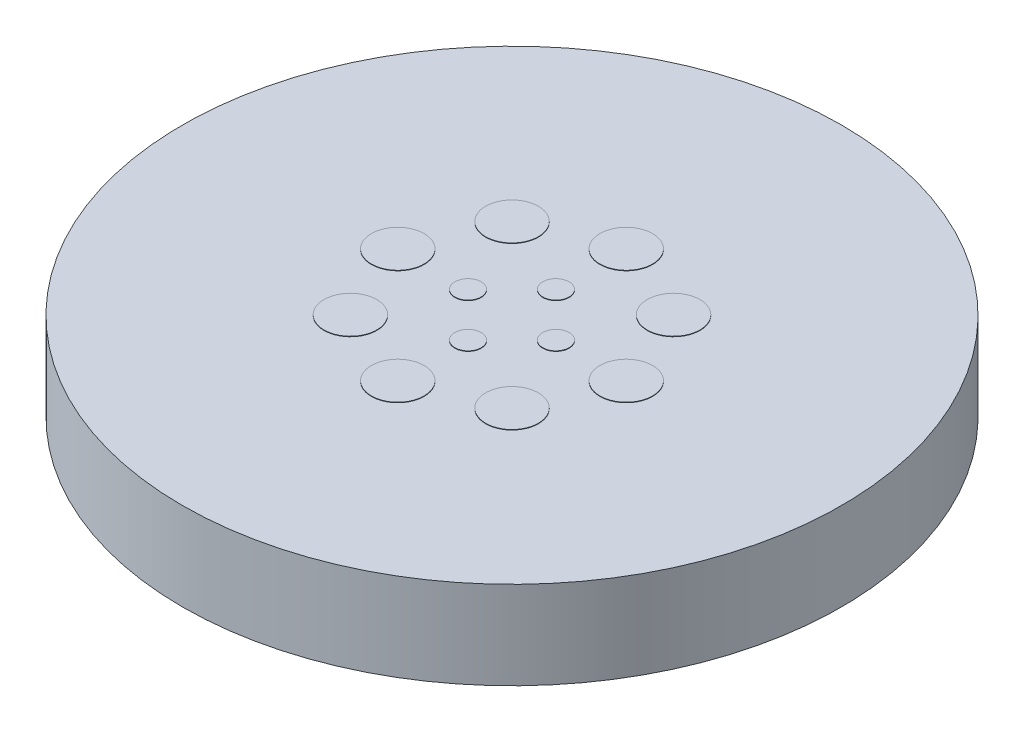
from build123d import *

# Parameters (mm, degrees)
SKETCH1_R           = 50.8
BOSS_EXTRUDE1_DEPTH = 25.4
SKETCH2_R           = 69.85
SKETCH2_R_2         = 50.8
BOSS_EXTRUDE2_DEPTH = 12.7
SKETCH3_R           = 49.53
SKETCH3_R_2         = 47.625
CUT_EXTRUDE1_DEPTH  = 1.1176
CUT_EXTRUDE2_REACH  = 103.996
SKETCH4_R           = 3.175
SKETCH5_R           = 11.43
CUT_EXTRUDE3_DEPTH  = 19.05
SKETCH42_OUTSIDE_W  = 181.538
SKETCH42_OUTSIDE_H  = 181.538
SKETCH42_OUTSIDE_R  = 23.8125
CUT_EXTRUDE9_DEPTH  = 30.48
SKETCH43_R          = 20.6375
CUT_EXTRUDE10_DEPTH = 19.05
CUT_EXTRUDE11_START = -19.05
SKETCH52_R          = 23.8125
CUT_EXTRUDE11_DEPTH = 19.05
SKETCH55_R          = 1.905
CUT_EXTRUDE12_DEPTH = 7.62
CIRPATTERN1_COUNT   = 8
SKETCH58_R          = 0.9525
CUT_EXTRUDE14_DEPTH = 7.62
CIRPATTERN2_COUNT   = 4
SKETCH59_R          = 0.9525
SKETCH59_R_2        = 1.905
INLET_LID_DEPTH     = 0.03175
SKETCH60_R          = 0.9525
SKETCH60_R_2        = 1.905
OUTLET_LID_DEPTH    = 0.0635


with BuildPart() as part:
    # Sketch1 → Boss-Extrude1 (new body)
    with BuildSketch(Plane(origin=(0, 0, 0), x_dir=(1, 0, 0), z_dir=(0, 1, 0))):
        Circle(SKETCH1_R)
    extrude(amount=BOSS_EXTRUDE1_DEPTH)

    # Sketch2 → Boss-Extrude2 (add)
    with BuildSketch(Plane.XZ):
        Circle(SKETCH2_R)
        Circle(SKETCH2_R_2, mode=Mode.SUBTRACT)
    extrude(amount=-BOSS_EXTRUDE2_DEPTH)

    # Sketch3 → Cut-Extrude1 (cut)
    with BuildSketch(Plane.XZ):
        Circle(SKETCH3_R)
        Circle(SKETCH3_R_2, mode=Mode.SUBTRACT)
    extrude(amount=-CUT_EXTRUDE1_DEPTH, mode=Mode.SUBTRACT)

    # Sketch4 → Cut-Extrude2 (cut, up to next)
    with BuildSketch(Plane.XZ, mode=Mode.PRIVATE) as cut_extrude2_sk1:
        with Locations((0, -59.9186)):
            Circle(SKETCH4_R)
    cut_extrude2_tool1 = extrude(cut_extrude2_sk1.sketch, amount=-CUT_EXTRUDE2_REACH, mode=Mode.PRIVATE) & part.part
    # Sketch4 → Cut-Extrude2 (cut, up to next)
    with BuildSketch(Plane.XZ, mode=Mode.PRIVATE) as cut_extrude2_sk2:
        with Locations((-42.368848379, -42.368848379)):
            Circle(SKETCH4_R)
    cut_extrude2_tool2 = extrude(cut_extrude2_sk2.sketch, amount=-CUT_EXTRUDE2_REACH, mode=Mode.PRIVATE) & part.part
    # Sketch4 → Cut-Extrude2 (cut, up to next)
    with BuildSketch(Plane.XZ, mode=Mode.PRIVATE) as cut_extrude2_sk3:
        with Locations((-59.9186, 0)):
            Circle(SKETCH4_R)
    cut_extrude2_tool3 = extrude(cut_extrude2_sk3.sketch, amount=-CUT_EXTRUDE2_REACH, mode=Mode.PRIVATE) & part.part
    # Sketch4 → Cut-Extrude2 (cut, up to next)
    with BuildSketch(Plane.XZ, mode=Mode.PRIVATE) as cut_extrude2_sk4:
        with Locations((-42.368848379, 42.368848379)):
            Circle(SKETCH4_R)
    cut_extrude2_tool4 = extrude(cut_extrude2_sk4.sketch, amount=-CUT_EXTRUDE2_REACH, mode=Mode.PRIVATE) & part.part
    # Sketch4 → Cut-Extrude2 (cut, up to next)
    with BuildSketch(Plane.XZ, mode=Mode.PRIVATE) as cut_extrude2_sk5:
        with Locations((0, 59.9186)):
            Circle(SKETCH4_R)
    cut_extrude2_tool5 = extrude(cut_extrude2_sk5.sketch, amount=-CUT_EXTRUDE2_REACH, mode=Mode.PRIVATE) & part.part
    # Sketch4 → Cut-Extrude2 (cut, up to next)
    with BuildSketch(Plane.XZ, mode=Mode.PRIVATE) as cut_extrude2_sk6:
        with Locations((42.368848379, 42.368848379)):
            Circle(SKETCH4_R)
    cut_extrude2_tool6 = extrude(cut_extrude2_sk6.sketch, amount=-CUT_EXTRUDE2_REACH, mode=Mode.PRIVATE) & part.part
    # Sketch4 → Cut-Extrude2 (cut, up to next)
    with BuildSketch(Plane.XZ, mode=Mode.PRIVATE) as cut_extrude2_sk7:
        with Locations((59.9186, 0)):
            Circle(SKETCH4_R)
    cut_extrude2_tool7 = extrude(cut_extrude2_sk7.sketch, amount=-CUT_EXTRUDE2_REACH, mode=Mode.PRIVATE) & part.part
    # Sketch4 → Cut-Extrude2 (cut, up to next)
    with BuildSketch(Plane.XZ, mode=Mode.PRIVATE) as cut_extrude2_sk8:
        with Locations((42.368848379, -42.368848379)):
            Circle(SKETCH4_R)
    cut_extrude2_tool8 = extrude(cut_extrude2_sk8.sketch, amount=-CUT_EXTRUDE2_REACH, mode=Mode.PRIVATE) & part.part
    add(cut_extrude2_tool1.solids().sort_by_distance((0, 0, -59.9186))[0], mode=Mode.SUBTRACT)
    add(cut_extrude2_tool2.solids().sort_by_distance((-42.368848, 0, -42.368848))[0], mode=Mode.SUBTRACT)
    add(cut_extrude2_tool3.solids().sort_by_distance((-59.9186, 0, 0))[0], mode=Mode.SUBTRACT)
    add(cut_extrude2_tool4.solids().sort_by_distance((-42.368848, 0, 42.368848))[0], mode=Mode.SUBTRACT)
    add(cut_extrude2_tool5.solids().sort_by_distance((0, 0, 59.9186))[0], mode=Mode.SUBTRACT)
    add(cut_extrude2_tool6.solids().sort_by_distance((42.368848, 0, 42.368848))[0], mode=Mode.SUBTRACT)
    add(cut_extrude2_tool7.solids().sort_by_distance((59.9186, 0, 0))[0], mode=Mode.SUBTRACT)
    add(cut_extrude2_tool8.solids().sort_by_distance((42.368848, 0, -42.368848))[0], mode=Mode.SUBTRACT)

    # Sketch5 → Cut-Extrude3 (cut)
    with BuildSketch(Plane(origin=(0, 25.4, 0), x_dir=(1, 0, 0), z_dir=(0, 1, 0))):
        Circle(SKETCH5_R)
    extrude(amount=-CUT_EXTRUDE3_DEPTH, mode=Mode.SUBTRACT)

    # Sketch42 outside → Cut-Extrude9 (cut)
    with BuildSketch(Plane.XZ):
        Rectangle(SKETCH42_OUTSIDE_W, SKETCH42_OUTSIDE_H)
        Circle(SKETCH42_OUTSIDE_R, mode=Mode.SUBTRACT)
    extrude(amount=-CUT_EXTRUDE9_DEPTH, mode=Mode.SUBTRACT)

    # Sketch43 → Cut-Extrude10 (cut)
    with BuildSketch(Plane(origin=(0, 25.4, 0), x_dir=(1, 0, 0), z_dir=(0, 1, 0))):
        Circle(SKETCH43_R)
    extrude(amount=-CUT_EXTRUDE10_DEPTH, mode=Mode.SUBTRACT)

    # Sketch52 → Cut-Extrude11 (cut)
    with BuildSketch(Plane(origin=(0, 25.4, 0), x_dir=(1, 0, 0), z_dir=(0, 1, 0)).offset(CUT_EXTRUDE11_START)):
        Circle(SKETCH52_R)
    extrude(amount=CUT_EXTRUDE11_DEPTH, mode=Mode.SUBTRACT)

    # Sketch55 → Cut-Extrude12 (cut)
    with BuildSketch(Plane.XZ):
        with Locations((8.255, 0)):
            Circle(SKETCH55_R)
    cut_extrude12 = extrude(amount=-CUT_EXTRUDE12_DEPTH, mode=Mode.SUBTRACT)

    # CirPattern1: Cut-Extrude12 ×8 about axis
    cirpattern1_axis = Axis((0, 0, 0), (0, -1, 0))
    for i in range(1, CIRPATTERN1_COUNT):
        add(cut_extrude12.rotate(cirpattern1_axis, i * 360 / CIRPATTERN1_COUNT), mode=Mode.SUBTRACT)

    # Sketch58 → Cut-Extrude14 (cut)
    with BuildSketch(Plane.XZ):
        with Locations((3.175, 0)):
            Circle(SKETCH58_R)
    cut_extrude14 = extrude(amount=-CUT_EXTRUDE14_DEPTH, mode=Mode.SUBTRACT)

    # CirPattern2: Cut-Extrude14 ×4 about axis
    cirpattern2_axis = Axis((0, 0, 0), (0, -1, 0))
    for i in range(1, CIRPATTERN2_COUNT):
        add(cut_extrude14.rotate(cirpattern2_axis, i * 360 / CIRPATTERN2_COUNT), mode=Mode.SUBTRACT)

    # Sketch59 → Inlet Lid (add, symmetric)
    with BuildSketch(Plane(origin=(0, 6.35, 0), x_dir=(1, 0, 0), z_dir=(0, 1, 0))):
        with Locations((0, -3.175)):
            Circle(SKETCH59_R)
        with Locations((-3.175, 0)):
            Circle(SKETCH59_R)
        with Locations((0, 3.175)):
            Circle(SKETCH59_R)
        with Locations((3.175, 0)):
            Circle(SKETCH59_R)
        with Locations((0, 8.255)):
            Circle(SKETCH59_R_2)
        with Locations((-5.837166479, 5.837166479)):
            Circle(SKETCH59_R_2)
        with Locations((-8.255, 0)):
            Circle(SKETCH59_R_2)
        with Locations((-5.837166479, -5.837166479)):
            Circle(SKETCH59_R_2)
        with Locations((0, -8.255)):
            Circle(SKETCH59_R_2)
        with Locations((5.837166479, -5.837166479)):
            Circle(SKETCH59_R_2)
        with Locations((8.255, 0)):
            Circle(SKETCH59_R_2)
        with Locations((5.837166479, 5.837166479)):
            Circle(SKETCH59_R_2)
    extrude(amount=INLET_LID_DEPTH, both=True)

    # Sketch60 → Outlet Lid (add, symmetric)
    with BuildSketch(Plane.XZ):
        with Locations((0, 3.175)):
            Circle(SKETCH60_R)
        with Locations((-3.175, 0)):
            Circle(SKETCH60_R)
        with Locations((0, -3.175)):
            Circle(SKETCH60_R)
        with Locations((3.175, 0)):
            Circle(SKETCH60_R)
        with Locations((5.837166479, 5.837166479)):
            Circle(SKETCH60_R_2)
        with Locations((0, 8.255)):
            Circle(SKETCH60_R_2)
        with Locations((-5.837166479, 5.837166479)):
            Circle(SKETCH60_R_2)
        with Locations((-8.255, 0)):
            Circle(SKETCH60_R_2)
        with Locations((-5.837166479, -5.837166479)):
            Circle(SKETCH60_R_2)
        with Locations((0, -8.255)):
            Circle(SKETCH60_R_2)
        with Locations((5.837166479, -5.837166479)):
            Circle(SKETCH60_R_2)
        with Locations((8.255, 0)):
            Circle(SKETCH60_R_2)
    extrude(amount=OUTLET_LID_DEPTH, both=True)


solid = part.part
